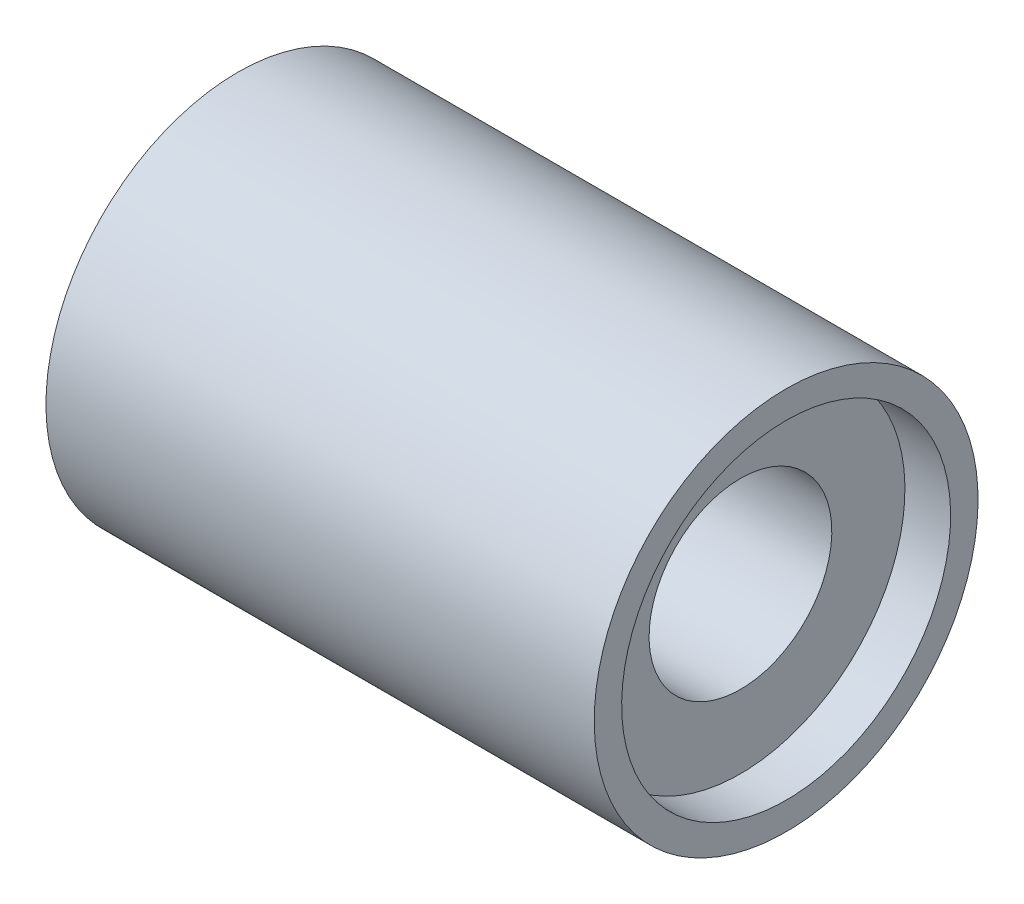
from build123d import *


with BuildPart() as part:
    # Esboço1 → Revolução1 (revolve)
    with BuildSketch(Plane.XY):
        Polygon((-6, 4.2), (6, 4.2), (6, 3.6), (5, 3.6), (5, 2), (-5, 2), (-5, 3), (-6, 3), align=None)
    revolve(axis=Axis((0, 0, 0), (-1, 0, 0)))


solid = part.part
